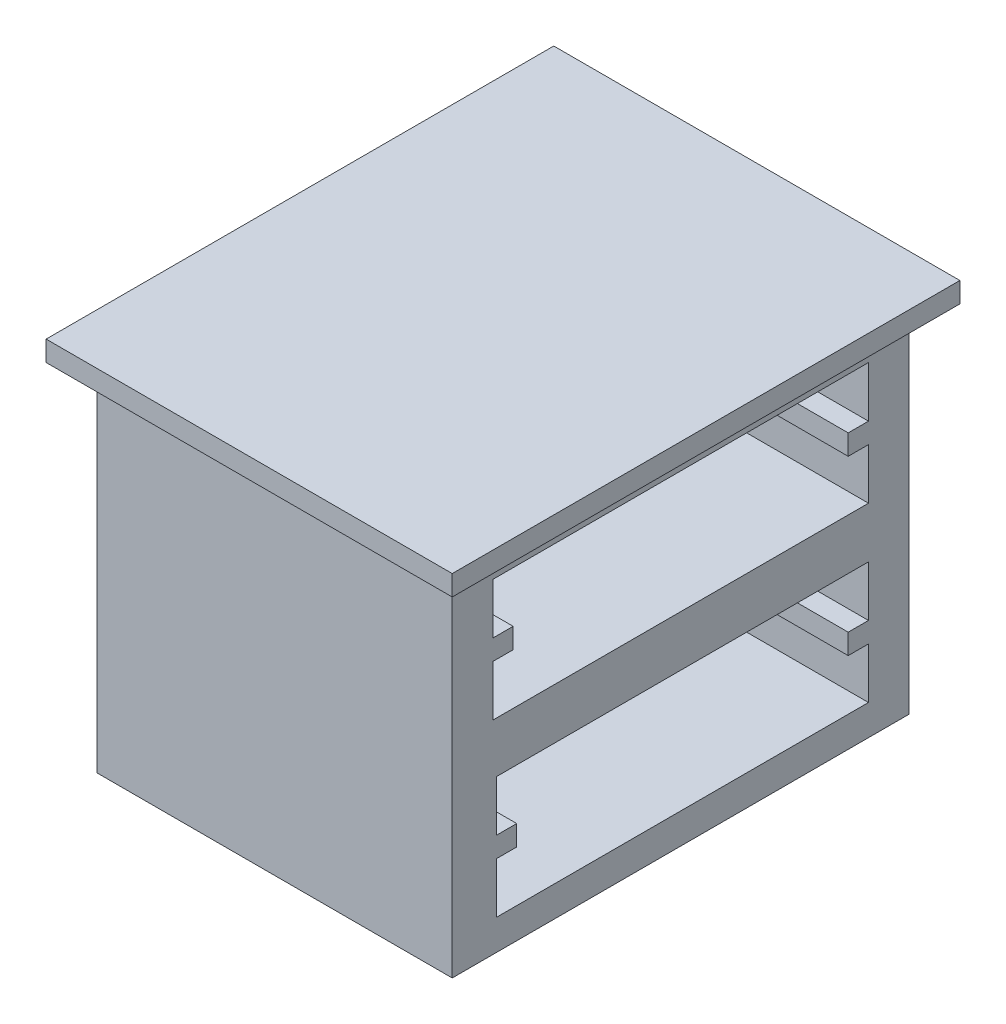
from build123d import *

# Parameters (mm, degrees)
SKETCH1_W           = 400
SKETCH1_H           = 500
BOSS_EXTRUDE1_DEPTH = 20
SKETCH2_W           = 350
SKETCH2_H           = 450
BOSS_EXTRUDE2_DEPTH = 350
CUT_EXTRUDE1_DEPTH  = 320


with BuildPart() as part:
    # Sketch1 → Boss-Extrude1 (new body)
    with BuildSketch(Plane(origin=(0, 0, 0), x_dir=(1, 0, 0), z_dir=(0, 1, 0))):
        Rectangle(SKETCH1_W, SKETCH1_H)
    extrude(amount=-BOSS_EXTRUDE1_DEPTH)

    # Sketch2 → Boss-Extrude2 (add)
    with BuildSketch(Plane.XZ.offset(20)):
        Rectangle(SKETCH2_W, SKETCH2_H)
    extrude(amount=BOSS_EXTRUDE2_DEPTH)

    # Sketch3 → Cut-Extrude1 (cut)
    with BuildSketch(Plane(origin=(175, 0, 0), x_dir=(0, 0, -1), z_dir=(1, 0, 0))):
        Polygon((-185, -50), (185, -50), (185, -100), (165, -100), (165, -120), (185, -120), (185, -170), (-185, -170), (-185, -120), (-165, -120), (-165, -100), (-185, -100), align=None)
        Polygon((-181.478873239, -220), (185, -220), (185, -270), (165, -270), (165, -290), (185, -290), (185, -340), (-181.478873239, -340), (-181.478873239, -290), (-161.478873239, -290), (-161.478873239, -270), (-181.478873239, -270), align=None)
    extrude(amount=-CUT_EXTRUDE1_DEPTH, mode=Mode.SUBTRACT)


solid = part.part
